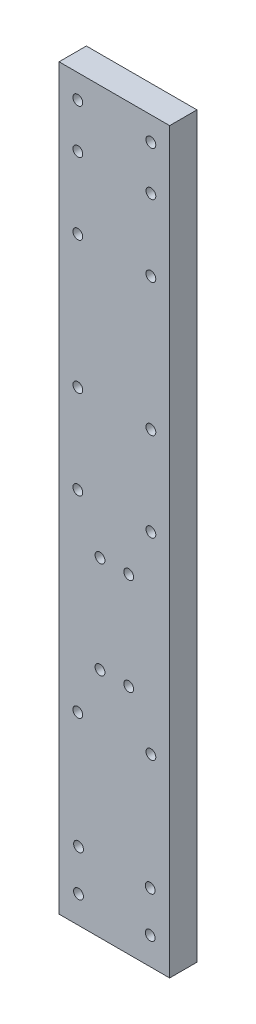
from build123d import *

# Parameters (mm, degrees)
SKETCH1_W           = 16.2
SKETCH1_H           = 108.14
SKETCH1_R           = 0.72
BOSS_EXTRUDE1_DEPTH = 4


with BuildPart() as part:
    # Sketch1 → Boss-Extrude1 (new body)
    with BuildSketch(Plane.XY):
        with Locations((8.1, 54.07)):
            Rectangle(SKETCH1_W, SKETCH1_H)
        with Locations((13.45, 55.21)):
            Circle(SKETCH1_R, mode=Mode.SUBTRACT)
        with Locations((10.2, 48.21)):
            Circle(SKETCH1_R, mode=Mode.SUBTRACT)
        with Locations((13.45, 104.66)):
            Circle(SKETCH1_R, mode=Mode.SUBTRACT)
        with Locations((2.75, 98.16)):
            Circle(SKETCH1_R, mode=Mode.SUBTRACT)
        with Locations((6, 48.21)):
            Circle(SKETCH1_R, mode=Mode.SUBTRACT)
        with Locations((2.75, 27)):
            Circle(SKETCH1_R, mode=Mode.SUBTRACT)
        with Locations((2.75, 87.66)):
            Circle(SKETCH1_R, mode=Mode.SUBTRACT)
        with Locations((2.75, 55.21)):
            Circle(SKETCH1_R, mode=Mode.SUBTRACT)
        with Locations((13.45, 87.66)):
            Circle(SKETCH1_R, mode=Mode.SUBTRACT)
        with Locations((13.45, 98.16)):
            Circle(SKETCH1_R, mode=Mode.SUBTRACT)
        with Locations((13.45, 68.21)):
            Circle(SKETCH1_R, mode=Mode.SUBTRACT)
        with Locations((6, 34)):
            Circle(SKETCH1_R, mode=Mode.SUBTRACT)
        with Locations((2.75, 104.66)):
            Circle(SKETCH1_R, mode=Mode.SUBTRACT)
        with Locations((10.2, 34)):
            Circle(SKETCH1_R, mode=Mode.SUBTRACT)
        with Locations((2.75, 68.21)):
            Circle(SKETCH1_R, mode=Mode.SUBTRACT)
        with Locations((13.45, 27)):
            Circle(SKETCH1_R, mode=Mode.SUBTRACT)
        with Locations((2.85, 10)):
            Circle(SKETCH1_R, mode=Mode.SUBTRACT)
        with Locations((13.35, 10)):
            Circle(SKETCH1_R, mode=Mode.SUBTRACT)
        with Locations((13.35, 4)):
            Circle(SKETCH1_R, mode=Mode.SUBTRACT)
        with Locations((2.85, 4)):
            Circle(SKETCH1_R, mode=Mode.SUBTRACT)
    extrude(amount=BOSS_EXTRUDE1_DEPTH)


solid = part.part
